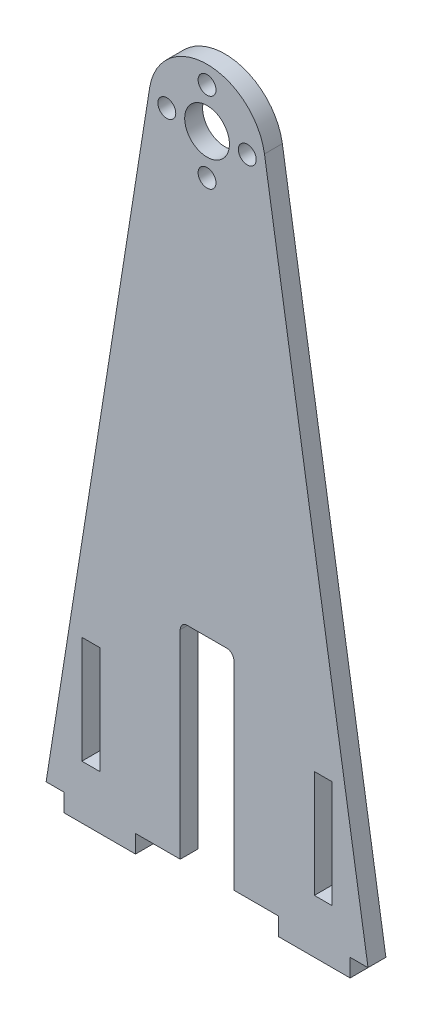
from build123d import *

# Parameters (mm, degrees)
SKETCH1_R           = 7.9375
SKETCH1_R_2         = 3.175
SKETCH1_W           = 6.35
SKETCH1_H           = 38.1
BOSS_EXTRUDE1_DEPTH = 6.35
FILLET1_R           = 2.54
FILLET2_R           = 2.54


with BuildPart() as part:
    # Sketch1 → Boss-Extrude1 (new body)
    with BuildSketch(Plane.XY):
        with BuildLine():
            Line((25.4, 0), (9.525, 0))
            Line((9.525, 0), (9.525, 73.166345412))
            Line((9.525, 73.166345412), (-9.525, 73.166345412))
            Line((-9.525, 73.166345412), (-9.525, 0))
            Line((-9.525, 0), (-25.4, 0))
            Line((-25.4, 0), (-25.4, -6.35))
            Line((-25.4, -6.35), (-50.8, -6.35))
            Line((-50.8, -6.35), (-50.8, 0))
            Line((-50.8, 0), (-57.15, 0))
            Line((-57.15, 0), (-20.382757931, 231.832581844))
            ThreePointArc((-20.382757931, 231.832581844), (0, 249.2375), (20.382757931, 231.832581844))
            Line((20.382757931, 231.832581844), (57.15, 0))
            Line((57.15, 0), (50.8, 0))
            Line((50.8, 0), (50.8, -6.35))
            Line((50.8, -6.35), (25.4, -6.35))
            Line((25.4, -6.35), (25.4, 0))
        make_face()
        with Locations((0, 228.6)):
            Circle(SKETCH1_R, mode=Mode.SUBTRACT)
        with Locations((0, 242.8875)):
            Circle(SKETCH1_R_2, mode=Mode.SUBTRACT)
        with Locations((14.2875, 228.6)):
            Circle(SKETCH1_R_2, mode=Mode.SUBTRACT)
        with Locations((0, 214.3125)):
            Circle(SKETCH1_R_2, mode=Mode.SUBTRACT)
        with Locations((-14.2875, 228.6)):
            Circle(SKETCH1_R_2, mode=Mode.SUBTRACT)
        with Locations((41.275, 31.75)):
            Rectangle(SKETCH1_W, SKETCH1_H, mode=Mode.SUBTRACT)
        with Locations((-41.275, 31.75)):
            Rectangle(SKETCH1_W, SKETCH1_H, mode=Mode.SUBTRACT)
    extrude(amount=BOSS_EXTRUDE1_DEPTH)

    # Fillet1
    fillet1_edges = [part.edges().sort_by_distance(p)[0] for p in [
        (-9.525, 73.166345412, 3.175),
    ]]
    fillet(fillet1_edges, radius=FILLET1_R)

    # Fillet2
    fillet2_edges = [part.edges().sort_by_distance(p)[0] for p in [
        (9.525, 73.166345412, 3.175),
    ]]
    fillet(fillet2_edges, radius=FILLET2_R)


solid = part.part
